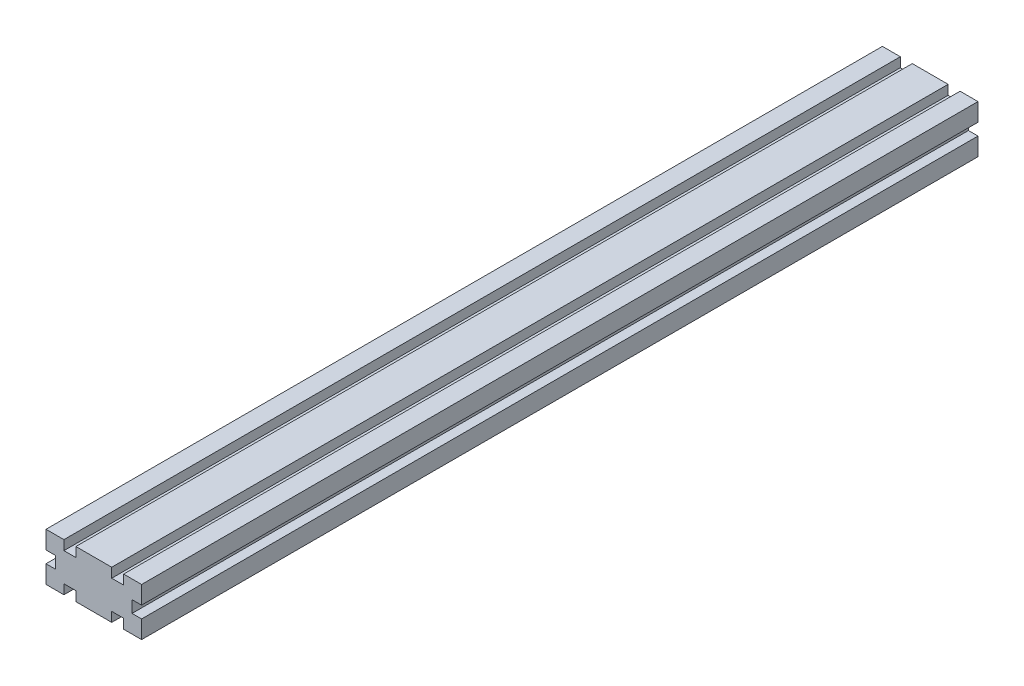
from build123d import *

# Parameters (mm, degrees)
ESQUISSE1_W        = 3.5
ESQUISSE1_H        = 5
ESQUISSE1_W_2      = 5
ESQUISSE1_H_2      = 3.5
ESQUISSE1_W_3      = 4
BOSS_EXTRU_1_DEPTH = 350


with BuildPart() as part:
    # Esquisse1 → Boss.-Extru.1 (new body)
    with BuildSketch(Plane.XY):
        Polygon((7.5, 16), (7.5, 20), (0, 20), (4, 16), align=None)
        Polygon((4, 16), (0, 20), (0, 12.5), (4, 12.5), align=None)
        Polygon((4, 7.5), (0, 7.5), (0, 0), (4, 4), align=None)
        Polygon((0, 0), (7.5, 0), (7.5, 4), (4, 4), align=None)
        Polygon((4, 4), (7.5, 7.5), (4, 7.5), align=None)
        Polygon((7.5, 4), (7.5, 7.5), (4, 4), align=None)
        Polygon((4, 12.5), (7.5, 12.5), (4, 16), align=None)
        Polygon((7.5, 12.5), (7.5, 16), (4, 16), align=None)
        with Locations((5.75, 10)):
            Rectangle(ESQUISSE1_W, ESQUISSE1_H)
        Polygon((7.5, 7.5), (10, 10), (7.5, 12.5), align=None)
        Polygon((10, 10), (12.5, 12.5), (7.5, 12.5), align=None)
        Polygon((12.5, 7.5), (12.5, 12.5), (10, 10), align=None)
        Polygon((12.5, 7.5), (10, 10), (7.5, 7.5), align=None)
        Polygon((16, 4), (12.5, 7.5), (12.5, 4), align=None)
        Polygon((16, 4), (16, 7.5), (12.5, 7.5), align=None)
        Polygon((20, 0), (20, 7.5), (16, 7.5), (16, 4), align=None)
        with Locations((10, 14.25)):
            Rectangle(ESQUISSE1_W_2, ESQUISSE1_H_2)
        with Locations((14.25, 10)):
            Rectangle(ESQUISSE1_W, ESQUISSE1_H)
        Polygon((12.5, 12.5), (16, 16), (12.5, 16), align=None)
        Polygon((16, 16), (20, 20), (12.5, 20), (12.5, 16), align=None)
        Polygon((16, 12.5), (16, 16), (12.5, 12.5), align=None)
        Polygon((20, 12.5), (20, 20), (16, 16), (16, 12.5), align=None)
        Polygon((12.5, 0), (20, 0), (16, 4), (12.5, 4), align=None)
        with Locations((10, 5.75)):
            Rectangle(ESQUISSE1_W_2, ESQUISSE1_H_2)
        with Locations((18, 10)):
            Rectangle(ESQUISSE1_W_3, ESQUISSE1_H)
        with Locations((22, 10)):
            Rectangle(ESQUISSE1_W_3, ESQUISSE1_H)
        Polygon((24, 16), (20, 20), (20, 12.5), (24, 12.5), align=None)
        Polygon((27.5, 20), (20, 20), (24, 16), (27.5, 16), align=None)
        Polygon((27.5, 12.5), (24, 16), (24, 12.5), align=None)
        Polygon((27.5, 16), (24, 16), (27.5, 12.5), align=None)
        with Locations((25.75, 10)):
            Rectangle(ESQUISSE1_W, ESQUISSE1_H)
        Polygon((27.5, 7.5), (24, 7.5), (24, 4), align=None)
        Polygon((24, 7.5), (20, 7.5), (20, 0), (24, 4), align=None)
        Polygon((24, 4), (20, 0), (27.5, 0), (27.5, 4), align=None)
        Polygon((27.5, 4), (27.5, 7.5), (24, 4), align=None)
        with Locations((30, 5.75)):
            Rectangle(ESQUISSE1_W_2, ESQUISSE1_H_2)
        Polygon((36, 4), (32.5, 7.5), (32.5, 4), align=None)
        Polygon((36, 7.5), (32.5, 7.5), (36, 4), align=None)
        Polygon((40, 0), (40, 7.5), (36, 7.5), (36, 4), align=None)
        Polygon((32.5, 4), (32.5, 0), (40, 0), (36, 4), align=None)
        with Locations((34.25, 10)):
            Rectangle(ESQUISSE1_W, ESQUISSE1_H)
        Polygon((32.5, 12.5), (30, 10), (32.5, 7.5), align=None)
        Polygon((32.5, 7.5), (30, 10), (27.5, 7.5), align=None)
        Polygon((30, 10), (27.5, 12.5), (27.5, 7.5), align=None)
        Polygon((32.5, 12.5), (27.5, 12.5), (30, 10), align=None)
        Polygon((36, 16), (32.5, 12.5), (36, 12.5), align=None)
        Polygon((36, 16), (32.5, 16), (32.5, 12.5), align=None)
        Polygon((40, 20), (32.5, 20), (32.5, 16), (36, 16), align=None)
        Polygon((40, 12.5), (40, 20), (36, 16), (36, 12.5), align=None)
        with Locations((30, 14.25)):
            Rectangle(ESQUISSE1_W_2, ESQUISSE1_H_2)
    extrude(amount=BOSS_EXTRU_1_DEPTH)


solid = part.part
